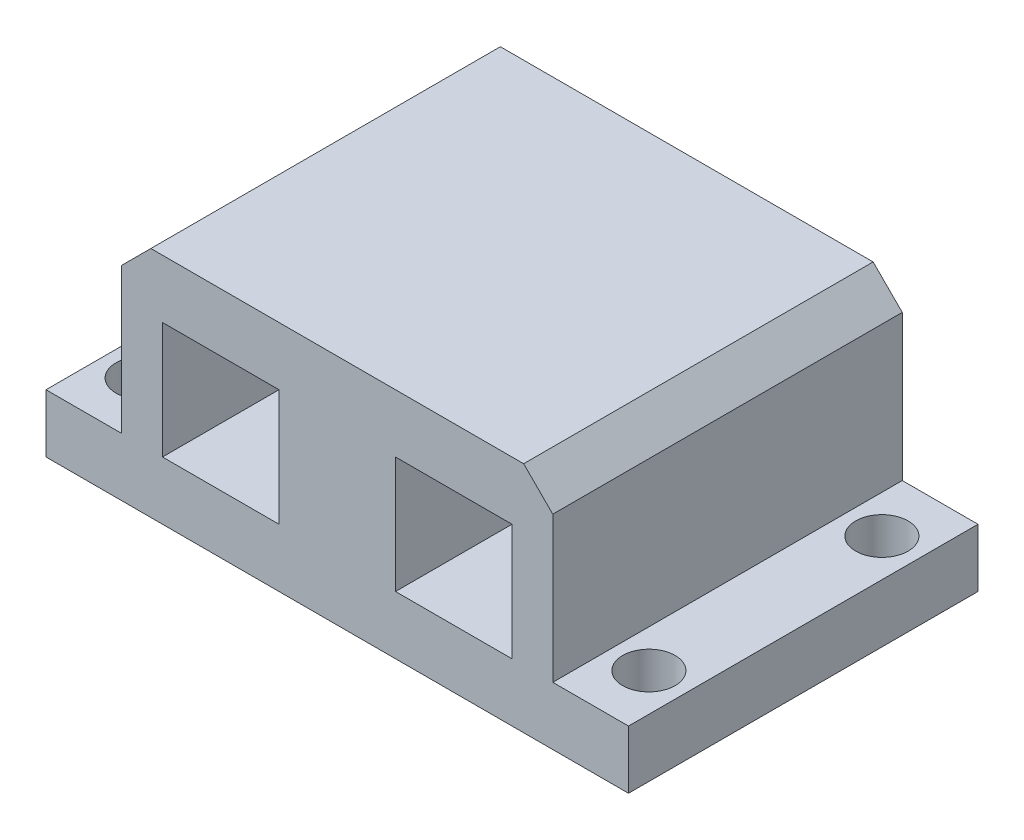
from build123d import *

# Parameters (mm, degrees)
SKETCH2_W           = 10
SKETCH2_H           = 10
BOSS_EXTRUDE1_DEPTH = 30
CHAMFER1_SIZE       = 2.5
SKETCH3_R           = 2.25
CUT_EXTRUDE1_DEPTH  = 6


with BuildPart() as part:
    # Sketch2 → Boss-Extrude1 (new body)
    with BuildSketch(Plane.XY):
        Polygon((-25, -10), (25, -10), (25, -5), (18.5, -5), (18.5, 10), (-18.5, 10), (-18.5, -5), (-25, -5), align=None)
        with Locations((-10, 0)):
            Rectangle(SKETCH2_W, SKETCH2_H, mode=Mode.SUBTRACT)
        with Locations((10, 0)):
            Rectangle(SKETCH2_W, SKETCH2_H, mode=Mode.SUBTRACT)
    extrude(amount=BOSS_EXTRUDE1_DEPTH)

    # Chamfer1
    chamfer1_edges = [part.edges().sort_by_distance(p)[0] for p in [
        (-18.5, 10, 15),
        (18.5, 10, 15),
    ]]
    chamfer(chamfer1_edges, length=CHAMFER1_SIZE)

    # Sketch3 → Cut-Extrude1 (cut, through all)
    with BuildSketch(Plane(origin=(0, -5, 0), x_dir=(1, 0, 0), z_dir=(0, 1, 0))):
        with Locations((-21.75, -5)):
            Circle(SKETCH3_R)
        with Locations((-21.75, -25)):
            Circle(SKETCH3_R)
        with Locations((21.75, -25)):
            Circle(SKETCH3_R)
        with Locations((21.75, -5)):
            Circle(SKETCH3_R)
    extrude(amount=-CUT_EXTRUDE1_DEPTH, mode=Mode.SUBTRACT)


solid = part.part
